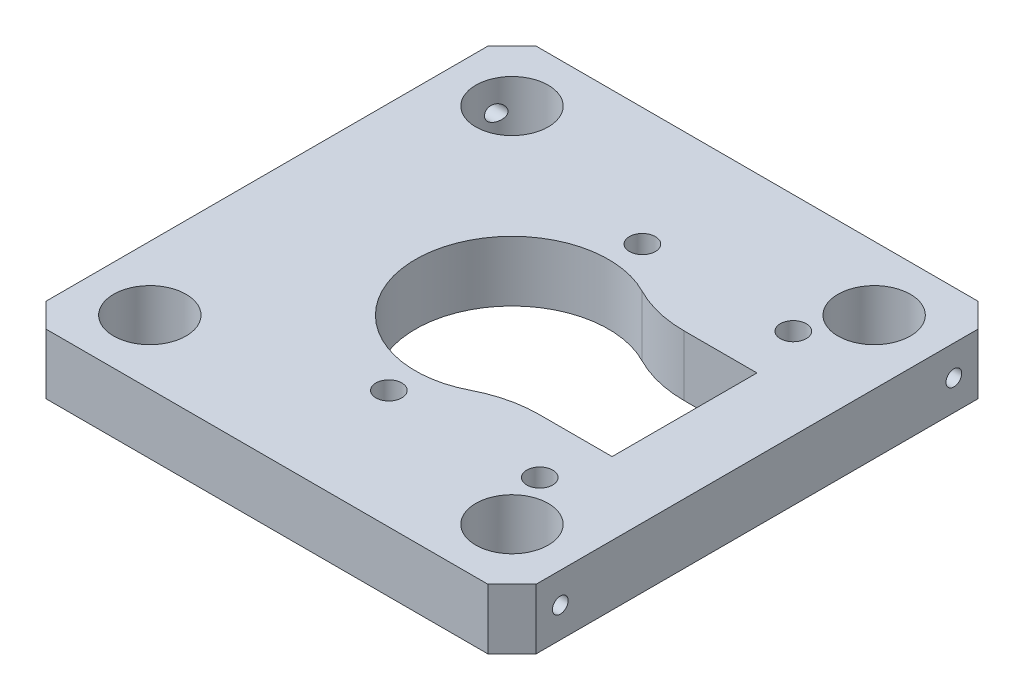
from build123d import *

# Parameters (mm, degrees)
SKETCH1_W           = 40.6
SKETCH1_H           = 40.6
BOSS_EXTRUDE1_DEPTH = 5
SKETCH2_R           = 8
CUT_EXTRUDE1_DEPTH  = 5
CUT_EXTRUDE3_DEPTH  = 6
SKETCH5_R           = 3
CUT_EXTRUDE4_DEPTH  = 10
CHAMFER1_SIZE       = 2
SKETCH6_R           = 0.65
CUT_EXTRUDE5_DEPTH  = 5
SKETCH7_R           = 0.65
CUT_EXTRUDE6_DEPTH  = 5
SKETCH8_R           = 1.075
CUT_EXTRUDE7_DEPTH  = 10
FILLET1_R           = 10


with BuildPart() as part:
    # Sketch1 → Boss-Extrude1 (new body)
    with BuildSketch(Plane(origin=(0, 0, 0), x_dir=(1, 0, 0), z_dir=(0, 1, 0))):
        Rectangle(SKETCH1_W, SKETCH1_H)
    extrude(amount=BOSS_EXTRUDE1_DEPTH)

    # Sketch2 → Cut-Extrude1 (cut)
    with BuildSketch(Plane(origin=(0, 5, 0), x_dir=(1, 0, 0), z_dir=(0, 1, 0))):
        Circle(SKETCH2_R)
    extrude(amount=-CUT_EXTRUDE1_DEPTH, mode=Mode.SUBTRACT)

    # Sketch4 → Cut-Extrude3 (cut, through all)
    with BuildSketch(Plane(origin=(0, 0, 0), x_dir=(-1, 0, 0), z_dir=(0, -1, 0))):
        Polygon((-5.291502622, 6), (-14.291502622, 6), (-14.291502622, 0), (-14.291502622, -6), (-5.291502622, -6), align=None)
    extrude(amount=-CUT_EXTRUDE3_DEPTH, mode=Mode.SUBTRACT)

    # Sketch5 → Cut-Extrude4 (cut)
    with BuildSketch(Plane(origin=(0, 5, 0), x_dir=(1, 0, 0), z_dir=(0, 1, 0))):
        with Locations((15, 15)):
            Circle(SKETCH5_R)
        with Locations((15, -15)):
            Circle(SKETCH5_R)
        with Locations((-15, -15)):
            Circle(SKETCH5_R)
        with Locations((-15, 15)):
            Circle(SKETCH5_R)
    extrude(amount=-CUT_EXTRUDE4_DEPTH, mode=Mode.SUBTRACT)

    # Chamfer1
    chamfer1_edges = [part.edges().sort_by_distance(p)[0] for p in [
        (20.3, 2.5, 20.3),
        (-20.3, 2.5, 20.3),
        (-20.3, 2.5, -20.3),
        (20.3, 2.5, -20.3),
    ]]
    chamfer(chamfer1_edges, length=CHAMFER1_SIZE)

    # Sketch6 → Cut-Extrude5 (cut)
    with BuildSketch(Plane.ZY.offset(20.3)):
        with Locations((-16.3, 2.5)):
            Circle(SKETCH6_R)
        with Locations((16.3, 2.5)):
            Circle(SKETCH6_R)
    extrude(amount=-CUT_EXTRUDE5_DEPTH, mode=Mode.SUBTRACT)

    # Sketch7 → Cut-Extrude6 (cut)
    with BuildSketch(Plane(origin=(20.3, 0, 0), x_dir=(0, 0, -1), z_dir=(1, 0, 0))):
        with Locations((16.3, 2.5)):
            Circle(SKETCH7_R)
        with Locations((-16.3, 2.5)):
            Circle(SKETCH7_R)
    extrude(amount=-CUT_EXTRUDE6_DEPTH, mode=Mode.SUBTRACT)

    # Sketch8 → Cut-Extrude7 (cut)
    with BuildSketch(Plane(origin=(0, 5, 0), x_dir=(1, 0, 0), z_dir=(0, 1, 0))):
        with Locations((0.3, -10.5)):
            Circle(SKETCH8_R)
        with Locations((12.8, -10.5)):
            Circle(SKETCH8_R)
        with Locations((0.3, 10.5)):
            Circle(SKETCH8_R)
        with Locations((12.8, 10.5)):
            Circle(SKETCH8_R)
    extrude(amount=-CUT_EXTRUDE7_DEPTH, mode=Mode.SUBTRACT)

    # Fillet1
    fillet1_edges = [part.edges().sort_by_distance(p)[0] for p in [
        (5.291502622, 2.5, -6),
        (5.291502622, 2.5, 6),
    ]]
    fillet(fillet1_edges, radius=FILLET1_R)


solid = part.part
